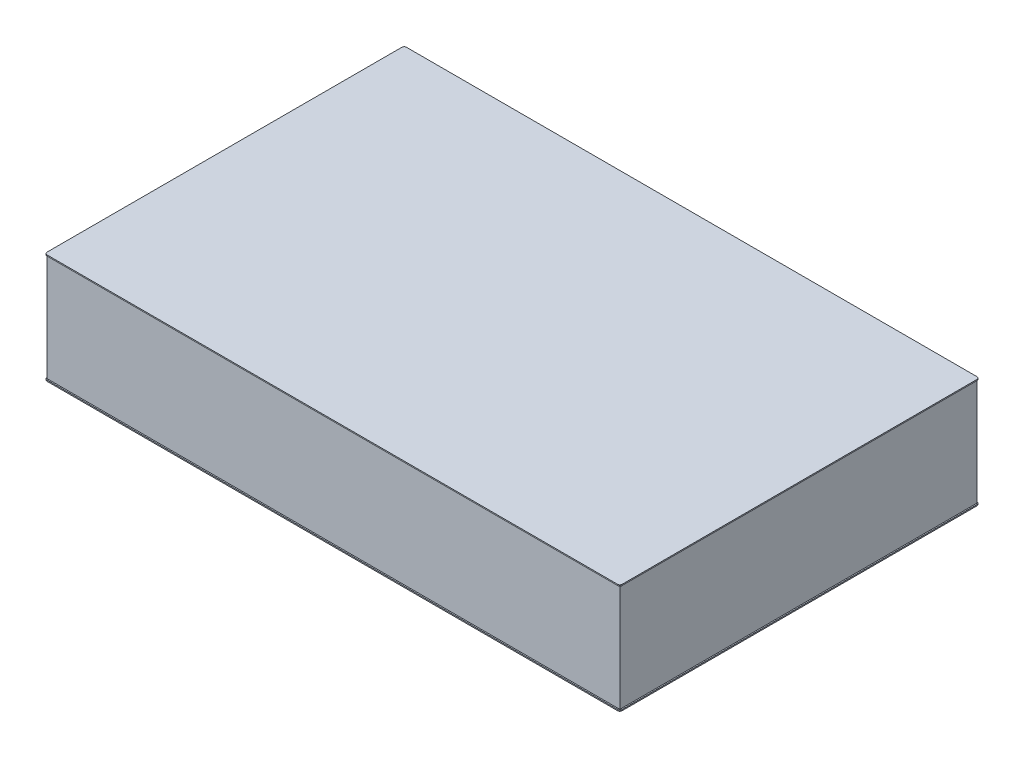
from build123d import *

# Parameters (mm, degrees)
BOSS_EXTRUDE2_DEPTH = 4.8
SKETCH4_W           = 2390
SKETCH4_H           = 1490
BOSS_EXTRUDE3_DEPTH = 447.4
BOSS_EXTRUDE4_DEPTH = 4.8


with BuildPart() as part:
    # Sketch1 → Boss-Extrude2 (new body)
    with BuildSketch(Plane(origin=(0, 0, 0), x_dir=(1, 0, 0), z_dir=(0, 1, 0))):
        with BuildLine():
            Line((-1190.348, -750), (1190.348, -750))
            ThreePointArc((1190.348, -750), (1197.172994652, -747.172994652), (1200, -740.348))
            Line((1200, -740.348), (1200, 740.348))
            ThreePointArc((1200, 740.348), (1197.172994652, 747.172994652), (1190.348, 750))
            Line((1190.348, 750), (-1190.348, 750))
            ThreePointArc((-1190.348, 750), (-1197.172994652, 747.172994652), (-1200, 740.348))
            Line((-1200, 740.348), (-1200, -740.348))
            ThreePointArc((-1200, -740.348), (-1197.172994652, -747.172994652), (-1190.348, -750))
        make_face()
    extrude(amount=-BOSS_EXTRUDE2_DEPTH)

    # Sketch4 → Boss-Extrude3 (add)
    with BuildSketch(Plane.XZ.offset(4.8)):
        Rectangle(SKETCH4_W, SKETCH4_H)
    extrude(amount=BOSS_EXTRUDE3_DEPTH)

    # Sketch5 → Boss-Extrude4 (add)
    with BuildSketch(Plane.XZ.offset(452.2)):
        with BuildLine():
            Line((1190.348, 750), (-1190.348, 750))
            ThreePointArc((-1190.348, 750), (-1197.172994652, 747.172994652), (-1200, 740.348))
            Line((-1200, 740.348), (-1200, -740.348))
            ThreePointArc((-1200, -740.348), (-1197.172994652, -747.172994652), (-1190.348, -750))
            Line((-1190.348, -750), (1190.348, -750))
            ThreePointArc((1190.348, -750), (1197.172994652, -747.172994652), (1200, -740.348))
            Line((1200, -740.348), (1200, 740.348))
            ThreePointArc((1200, 740.348), (1197.172994652, 747.172994652), (1190.348, 750))
        make_face()
    extrude(amount=BOSS_EXTRUDE4_DEPTH)


solid = part.part
